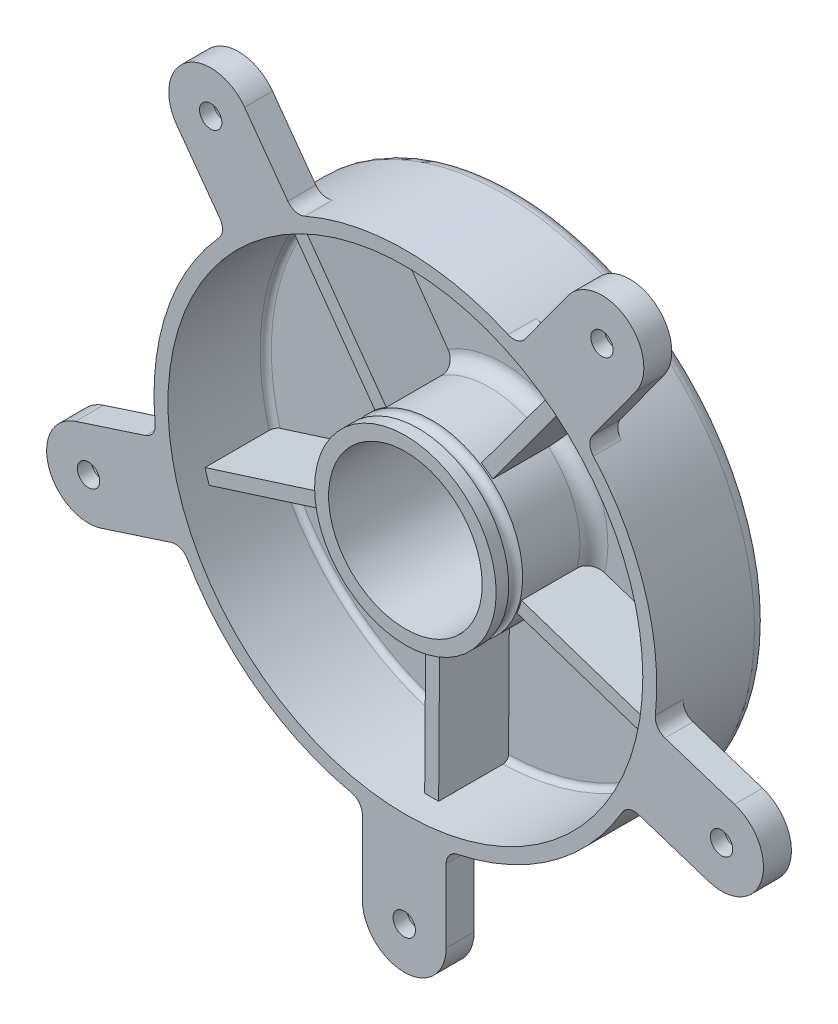
from build123d import *

# Parameters (mm, degrees)
IZIM1_R                       = 90
IZIM1_R_2                     = 85
Y_KSEKLIK_EKSTR_ZYON1_DEPTH   = 40
IZIM1_R_3                     = 32.5
IZIM1_R_4                     = 27.5
Y_KSEKLIK_EKSTR_ZYON1_2_DEPTH = 40
IZIM2_R                       = 85
Y_KSEKLIK_EKSTR_ZYON2_DEPTH   = 5
Y_KSEKLIK_EKSTR_ZYON3_DEPTH   = 30
IZIM5_R                       = 4
Y_KSEKLIK_EKSTR_ZYON4_DEPTH   = 10
IZIM6_R                       = 7.5
KES_EKSTR_ZYON2_DEPTH         = 5
RADYUS6_R                     = 2
RADYUS7_R                     = 5
RADYUS8_R                     = 5
IZIM7_R                       = 27.5
KES_EKSTR_ZYON3_DEPTH         = 45
IZIM8_R                       = 2.49


with BuildPart() as part:
    # Çizim1 → Yükseklik-Ekstrüzyon1 (new body)
    with BuildSketch(Plane.XY):
        Circle(IZIM1_R)
        Circle(IZIM1_R_2, mode=Mode.SUBTRACT)
    extrude(amount=Y_KSEKLIK_EKSTR_ZYON1_DEPTH)



with BuildPart() as body_2:
    # Çizim1 → Y_kseklik-Ekstr_zyon1 2 (new body)
    with BuildSketch(Plane.XY):
        Circle(IZIM1_R_3)
        Circle(IZIM1_R_4, mode=Mode.SUBTRACT)
    extrude(amount=Y_KSEKLIK_EKSTR_ZYON1_2_DEPTH)


with BuildPart() as part_1:
    add(part.part)

    add(body_2.part)  # Yükseklik-Ekstrüzyon2 merges body 2
    # Çizim2 → Yükseklik-Ekstrüzyon2 (add)
    with BuildSketch(Plane.XY):
        Circle(IZIM2_R)
    extrude(amount=Y_KSEKLIK_EKSTR_ZYON2_DEPTH)

    # Çizim3 → Yükseklik-Ekstrüzyon3 (add)
    with BuildSketch(Plane.XY):
        with BuildLine():
            ThreePointArc((-47.428469753, 70.537509574), (-49.482583905, 69.112038677), (-51.493883793, 67.626769344))
            Line((-51.493883793, 67.626769344), (-20.896459689, 24.891524109))
            ThreePointArc((-20.896459689, 24.891524109), (-18.919811493, 26.425191259), (-16.831045649, 27.802264339))
            Line((-16.831045649, 27.802264339), (-47.428469753, 70.537509574))
        make_face()
        with BuildLine():
            ThreePointArc((52.428954953, 66.904444415), (50.438495386, 68.417528333), (48.404394463, 69.871414732))
            Line((48.404394463, 69.871414732), (17.215885038, 27.56561812))
            ThreePointArc((17.215885038, 27.56561812), (19.285307059, 26.159643186), (21.240445528, 24.598647803))
            Line((21.240445528, 24.598647803), (52.428954953, 66.904444415))
        make_face()
        with BuildLine():
            ThreePointArc((79.831345908, -29.188288927), (80.655288395, -26.827680741), (81.409444775, -24.443860198))
            Line((81.409444775, -24.443860198), (31.536461789, -7.85503519))
            ThreePointArc((31.536461789, -7.85503519), (30.838786739, -10.257642636), (29.958362922, -12.599463919))
            Line((29.958362922, -12.599463919), (79.831345908, -29.188288927))
        make_face()
        with BuildLine():
            Line((-2.725158995, -32.385544745), (-3.090469814, -84.943799046))
            ThreePointArc((-3.090469814, -84.943799046), (-0.590785786, -84.99794687), (1.909409414, -84.978551151))
            Line((1.909409414, -84.978551151), (2.274720232, -32.42029685))
            ThreePointArc((2.274720232, -32.42029685), (-0.225888683, -32.49921498), (-2.725158995, -32.385544745))
        make_face()
        with BuildLine():
            Line((-31.642603806, -7.415903478), (-81.741361294, -23.309866017))
            ThreePointArc((-81.741361294, -23.309866017), (-81.02041409, -25.703939399), (-80.229364859, -28.075772728))
            Line((-80.229364859, -28.075772728), (-30.13060737, -12.181810189))
            ThreePointArc((-30.13060737, -12.181810189), (-30.978393623, -9.827976829), (-31.642603806, -7.415903478))
        make_face()
    extrude(amount=Y_KSEKLIK_EKSTR_ZYON3_DEPTH)

    # Çizim5 → Yükseklik-Ekstrüzyon4 (add)
    with BuildSketch(Plane.XY.offset(40)):
        with BuildLine():
            ThreePointArc((89.490701767, -9.561082434), (85.472135229, -28.187126484), (77.622323556, -45.549696878))
            ThreePointArc((77.622323556, -45.549696878), (80.159340513, -43.406031069), (83.479759837, -43.324953012))
            Line((83.479759837, -43.324953012), (108.555994506, -51.472715564))
            ThreePointArc((108.555994506, -51.472715564), (127.457097166, -41.842122735), (117.826504337, -22.941020075))
            Line((117.826504337, -22.941020075), (92.917322448, -14.847536262))
            ThreePointArc((92.917322448, -14.847536262), (90.266720524, -12.811851347), (89.490701767, -9.561082434))
        make_face()
        with Locations((113.191249421, -37.206867819)):
            Circle(IZIM5_R, mode=Mode.SUBTRACT)
        with BuildLine():
            ThreePointArc((36.747277436, 82.156178106), (53.21989265, 72.578530065), (67.306953153, 59.747586204))
            ThreePointArc((67.306953153, 59.747586204), (66.052187171, 62.822861878), (67.001143357, 66.00582281))
            Line((67.001143357, 66.00582281), (82.499108692, 87.336942102))
            ThreePointArc((82.499108692, 87.336942102), (79.180632561, 108.288975802), (58.228598861, 104.970499671))
            Line((58.228598861, 104.970499671), (42.833877821, 83.781483962))
            ThreePointArc((42.833877821, 83.781483962), (40.078745378, 81.889672963), (36.747277436, 82.156178106))
        make_face()
        with Locations((70.363853776, 96.153720886)):
            Circle(IZIM5_R, mode=Mode.SUBTRACT)
        with BuildLine():
            ThreePointArc((-66.444530085, 66.627340978), (-65.496693654, 63.422452566), (-66.779635317, 60.33639289))
            ThreePointArc((-66.779635317, 60.33639289), (-52.580432693, 73.043124918), (-36.024338828, 82.475735898))
            ThreePointArc((-36.024338828, 82.475735898), (-39.33684381, 82.23269498), (-42.070775957, 84.118794965))
            Line((-42.070775957, 84.118794965), (-57.568741293, 105.449914256))
            ThreePointArc((-57.568741293, 105.449914256), (-78.520774993, 108.768390387), (-81.839251124, 87.816356687))
            Line((-81.839251124, 87.816356687), (-66.444530085, 66.627340978))
        make_face()
        with Locations((-69.703996208, 96.633135472)):
            Circle(IZIM5_R, mode=Mode.SUBTRACT)
        with BuildLine():
            ThreePointArc((-83.89885578, -42.603522657), (-80.557928207, -42.692441628), (-78.019361819, -44.866236542))
            ThreePointArc((-78.019361819, -44.866236542), (-85.716387198, -27.435396221), (-89.571218971, -8.774778172))
            ThreePointArc((-89.571218971, -8.774778172), (-90.363693656, -12.000261394), (-93.002312831, -14.01754843))
            Line((-93.002312831, -14.01754843), (-118.0785475, -22.165310981))
            ThreePointArc((-118.0785475, -22.165310981), (-127.709140329, -41.066413641), (-108.808037669, -50.69700647))
            Line((-108.808037669, -50.69700647), (-83.89885578, -42.603522657))
        make_face()
        with Locations((-113.443292585, -36.431158725)):
            Circle(IZIM5_R, mode=Mode.SUBTRACT)
        with BuildLine():
            ThreePointArc((-15.407814405, -119.148829813), (-0.407814405, -134.148829813), (14.592185595, -119.148829813))
            Line((14.592185595, -119.148829813), (14.592185595, -92.957766021))
            ThreePointArc((14.592185595, -92.957766021), (15.709155959, -89.807832555), (18.561017932, -88.06525202))
            ThreePointArc((18.561017932, -88.06525202), (-0.395207987, -89.999132277), (-19.33371891, -87.898847052))
            ThreePointArc((-19.33371891, -87.898847052), (-16.510990219, -89.649264395), (-15.407814405, -92.782116333))
            Line((-15.407814405, -92.782116333), (-15.407814405, -119.148829813))
        make_face()
        with Locations((-0.407814405, -119.148829813)):
            Circle(IZIM5_R, mode=Mode.SUBTRACT)
    extrude(amount=-Y_KSEKLIK_EKSTR_ZYON4_DEPTH)

    # Çizim6 → Kes-Ekstrüzyon2 (cut)
    with BuildSketch(Plane(origin=(0, 0, 30), x_dir=(-1, 0, 0), z_dir=(0, 0, -1))):
        with Locations((-70.362044759, 96.154308672)):
            Circle(IZIM6_R)
        with Locations((113.443983568, -36.432109782)):
            Circle(IZIM6_R)
        with Locations((-113.190558438, -37.205916763)):
            Circle(IZIM6_R)
        with Locations((69.705805225, 96.632547686)):
            Circle(IZIM6_R)
        with Locations((0.407814405, -119.148829813)):
            Circle(IZIM6_R)
    extrude(amount=-KES_EKSTR_ZYON2_DEPTH, mode=Mode.SUBTRACT)

    # Radyus6
    radyus6_edges = [part_1.edges().sort_by_distance(p)[0] for p in [
        (-50.438495386, -68.417528333, 5),
        (-80.655288395, 26.827680741, 5),
        (0.590785786, 84.99794687, 5),
        (76.424672623, 37.205771253, 5),
        (49.482583905, -69.112038677, 5),
    ]]
    fillet(radyus6_edges, radius=RADYUS6_R)

    # Radyus7
    radyus7_edges = [part_1.edges().sort_by_distance(p)[0] for p in [
        (0.225888683, 32.49921498, 5),
        (29.551349205, 13.526557587, 5),
        (18.919811493, -26.425191259, 5),
        (-19.285307059, -26.159643186, 5),
        (-30.838786739, 10.257642636, 5),
    ]]
    fillet(radyus7_edges, radius=RADYUS7_R)

    # Radyus8
    radyus8_edges = [part_1.edges().sort_by_distance(p)[0] for p in [
        (-90, 0, 0),
    ]]
    fillet(radyus8_edges, radius=RADYUS8_R)

    # Çizim7 → Kes-Ekstrüzyon3 (cut)
    with BuildSketch(Plane.XY.offset(5)):
        Circle(IZIM7_R)
    extrude(amount=-KES_EKSTR_ZYON3_DEPTH, mode=Mode.SUBTRACT)

    # Çizim8 → Kes-Döndür1 (revolve, cut)
    with BuildSketch(Plane(origin=(0, 0, 0), x_dir=(1, 0, 0), z_dir=(0, 1, 0))):
        with Locations((-32.5, -33)):
            Circle(IZIM8_R)
    revolve(axis=Axis((0, 0, 0), (0, 0, 1)), mode=Mode.SUBTRACT)


solid = part_1.part
